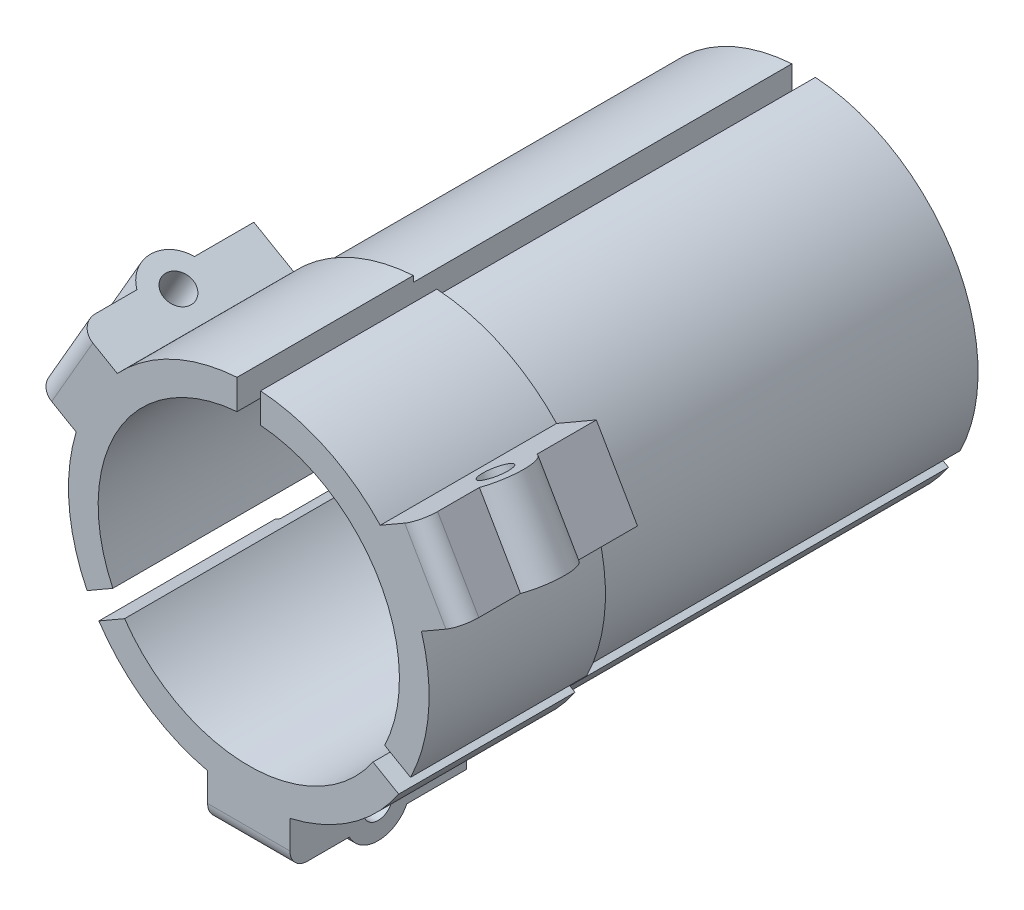
from build123d import *

# Parameters (mm, degrees)
BOSS_EXTRUDE1_DEPTH   = 11.9888
BOSS_EXTRUDE1_2_DEPTH = 11.9888
BOSS_EXTRUDE1_3_DEPTH = 11.9888
BOSS_EXTRUDE2_START   = -3.81
BOSS_EXTRUDE2_DEPTH   = 3.81
BOSS_EXTRUDE3_START   = -3.81
BOSS_EXTRUDE3_DEPTH   = 3.81
FILLET1_R             = 0.381
FILLET2_R             = 0.381
FILLET3_R             = 0.381
BOSS_EXTRUDE4_DEPTH   = 1.778
SKETCH5_6_R           = 0.3175
CUT_EXTRUDE1_DEPTH    = 1.778
BOSS_EXTRUDE5_DEPTH   = 1.778
CUT_EXTRUDE2_DEPTH    = 14.935215559
BOSS_EXTRUDE6_DEPTH   = 1.778
CUT_EXTRUDE3_DEPTH    = 15.288111882


with BuildPart() as part:
    # Sketch1 → Boss-Extrude1 (new body)
    with BuildSketch(Plane.XY):
        with BuildLine():
            Line((-0.254, 3.760702479), (-0.254, 3.244994166))
            ThreePointArc((-0.254, 3.244994166), (-2.818843265, 1.627459918), (-2.937247383, -1.402526631))
            Line((-2.937247383, -1.402526631), (-3.383863883, -1.660380787))
            ThreePointArc((-3.383863883, -1.660380787), (-3.264283896, 1.884635186), (-0.254, 3.760702479))
        make_face()
    extrude(amount=BOSS_EXTRUDE1_DEPTH)



with BuildPart() as body_2:
    # Sketch1 → Boss-Extrude1 2 (new body)
    with BuildSketch(Plane.XY):
        with BuildLine():
            Line((0.254, 3.760702479), (0.254, 3.244994166))
            ThreePointArc((0.254, 3.244994166), (2.818843265, 1.627459918), (2.937247383, -1.402526631))
            Line((2.937247383, -1.402526631), (3.383863883, -1.660380787))
            ThreePointArc((3.383863883, -1.660380787), (3.264283896, 1.884635186), (0.254, 3.760702479))
        make_face()
    extrude(amount=BOSS_EXTRUDE1_2_DEPTH)


with BuildPart() as body_3:
    # Sketch1 → Boss-Extrude1 3 (new body)
    with BuildSketch(Plane.XY):
        with BuildLine():
            Line((3.129863883, -2.100321692), (2.683247383, -1.842467536))
            ThreePointArc((2.683247383, -1.842467536), (0, -3.254919836), (-2.683247383, -1.842467536))
            Line((-2.683247383, -1.842467536), (-3.129863883, -2.100321692))
            ThreePointArc((-3.129863883, -2.100321692), (0, -3.769270372), (3.129863883, -2.100321692))
        make_face()
    extrude(amount=BOSS_EXTRUDE1_3_DEPTH)


with BuildPart() as part_1:
    add(part.part)

    add(body_2.part)  # Boss-Extrude2 merges body 2

    add(body_3.part)  # Boss-Extrude2 merges body 3
    # Sketch2 → Boss-Extrude2 (add)
    with BuildSketch(Plane.XY.offset(11.9888).offset(BOSS_EXTRUDE2_START)):
        with BuildLine():
            Line((-0.254, 3.760702479), (-0.254, 3.887982358))
            ThreePointArc((-0.254, 3.887982358), (-3.374269122, 1.948135186), (-3.494091491, -1.724020726))
            Line((-3.494091491, -1.724020726), (-3.383863883, -1.660380787))
            ThreePointArc((-3.383863883, -1.660380787), (-3.264283896, 1.884635186), (-0.254, 3.760702479))
        make_face()
        with BuildLine():
            Line((0.254, 3.887982358), (0.254, 3.760702479))
            ThreePointArc((0.254, 3.760702479), (3.264283896, 1.884635186), (3.383863883, -1.660380787))
            Line((3.383863883, -1.660380787), (3.494091491, -1.724020726))
            ThreePointArc((3.494091491, -1.724020726), (3.374269122, 1.948135186), (0.254, 3.887982358))
        make_face()
        with BuildLine():
            Line((3.240091491, -2.163961631), (3.129863883, -2.100321692))
            ThreePointArc((3.129863883, -2.100321692), (0, -3.769270372), (-3.129863883, -2.100321692))
            Line((-3.129863883, -2.100321692), (-3.240091491, -2.163961631))
            ThreePointArc((-3.240091491, -2.163961631), (0, -3.896270372), (3.240091491, -2.163961631))
        make_face()
    extrude(amount=BOSS_EXTRUDE2_DEPTH)

    # Sketch4 → Boss-Extrude3 (add)
    with BuildSketch(Plane.XY.offset(11.9888).offset(BOSS_EXTRUDE3_START)):
        with BuildLine():
            Line((-2.840762754, 2.666643919), (-3.699665706, 3.16253177))
            Line((-3.699665706, 3.16253177), (-4.588665706, 1.622738602))
            Line((-4.588665706, 1.622738602), (-3.729762754, 1.126850751))
            ThreePointArc((-3.729762754, 1.126850751), (-3.374269122, 1.948135186), (-2.840762754, 2.666643919))
        make_face()
        with BuildLine():
            Line((-0.889, -3.79349467), (-0.889, -4.785270372))
            Line((-0.889, -4.785270372), (0.889, -4.785270372))
            Line((0.889, -4.785270372), (0.889, -3.79349467))
            ThreePointArc((0.889, -3.79349467), (0, -3.896270372), (-0.889, -3.79349467))
        make_face()
        with BuildLine():
            Line((3.729762754, 1.126850751), (4.588665706, 1.622738602))
            Line((4.588665706, 1.622738602), (3.699665706, 3.16253177))
            Line((3.699665706, 3.16253177), (2.840762754, 2.666643919))
            ThreePointArc((2.840762754, 2.666643919), (3.374269122, 1.948135186), (3.729762754, 1.126850751))
        make_face()
    extrude(amount=BOSS_EXTRUDE3_DEPTH)

    # Fillet1
    fillet1_edges = [part_1.edges().sort_by_distance(p)[0] for p in [
        (-4.144165706, 2.392635186, 11.9888),
    ]]
    fillet(fillet1_edges, radius=FILLET1_R)

    # Fillet2
    fillet2_edges = [part_1.edges().sort_by_distance(p)[0] for p in [
        (0, -4.785270372, 11.9888),
    ]]
    fillet(fillet2_edges, radius=FILLET2_R)

    # Fillet3
    fillet3_edges = [part_1.edges().sort_by_distance(p)[0] for p in [
        (4.144165706, 2.392635186, 11.9888),
    ]]
    fillet(fillet3_edges, radius=FILLET3_R)

    # Sketch5 → Boss-Extrude4 (add)
    with BuildSketch(Plane(origin=(-0.4445, 0.769896584, 0), x_dir=(0.8660254037844434, 0.4999999999999918, 0), z_dir=(-0.4999999999999918, 0.8660254037844434, 0))):
        with BuildLine():
            ThreePointArc((4.785270372, -10.705970395), (5.166270372, -10.0838), (4.785270372, -9.461629605))
            Line((4.785270372, -9.461629605), (4.785270372, -10.0838))
            Line((4.785270372, -10.0838), (4.785270372, -10.705970395))
        make_face()
    extrude(amount=-BOSS_EXTRUDE4_DEPTH)

    # Sketch5_6 → Cut-Extrude1 (cut)
    with BuildSketch(Plane(origin=(-0.4445, 0.769896584, 0), x_dir=(0.8660254037844434, 0.4999999999999918, 0), z_dir=(-0.4999999999999918, 0.8660254037844434, 0))):
        with Locations((4.467770372, -10.0838)):
            Circle(SKETCH5_6_R)
    extrude(amount=-CUT_EXTRUDE1_DEPTH, mode=Mode.SUBTRACT)

    # Sketch6 → Boss-Extrude5 (add)
    with BuildSketch(Plane(origin=(-0.4445, -0.769896584, 0), x_dir=(0.8660254037844363, -0.5000000000000043, 0), z_dir=(-0.5000000000000042, -0.8660254037844362, 0))):
        with BuildLine():
            ThreePointArc((-4.785270372, 10.705970395), (-5.166270372, 10.0838), (-4.785270372, 9.461629605))
            Line((-4.785270372, 9.461629605), (-4.785270372, 10.0838))
            Line((-4.785270372, 10.0838), (-4.785270372, 10.705970395))
        make_face()
    extrude(amount=-BOSS_EXTRUDE5_DEPTH)

    # Sketch6_3 → Cut-Extrude2 (cut, through all)
    with BuildSketch(Plane(origin=(-0.4445, -0.769896584, 0), x_dir=(0.8660254037844363, -0.5000000000000043, 0), z_dir=(-0.5000000000000042, -0.8660254037844362, 0))):
        with BuildLine():
            ThreePointArc((-4.150270372, 10.0838), (-4.467770372, 10.4013), (-4.785270372, 10.0838))
            ThreePointArc((-4.785270372, 10.0838), (-4.467770372, 9.7663), (-4.150270372, 10.0838))
        make_face()
    extrude(amount=-CUT_EXTRUDE2_DEPTH, mode=Mode.SUBTRACT)

    # Sketch7 → Boss-Extrude6 (add)
    with BuildSketch(Plane(origin=(0.889, 0, 0), x_dir=(0, 0, -1), z_dir=(1, 0, 0))):
        with BuildLine():
            ThreePointArc((-10.705970395, -4.785270372), (-10.0838, -5.166270372), (-9.461629605, -4.785270372))
            Line((-9.461629605, -4.785270372), (-10.0838, -4.785270372))
            Line((-10.0838, -4.785270372), (-10.705970395, -4.785270372))
        make_face()
    extrude(amount=-BOSS_EXTRUDE6_DEPTH)

    # Sketch7_3 → Cut-Extrude3 (cut, through all)
    with BuildSketch(Plane(origin=(0.889, 0, 0), x_dir=(0, 0, -1), z_dir=(1, 0, 0))):
        with BuildLine():
            ThreePointArc((-9.7663, -4.467770372), (-10.308306403, -4.243263969), (-10.0838, -4.785270372))
            ThreePointArc((-10.0838, -4.785270372), (-9.859293597, -4.692276775), (-9.7663, -4.467770372))
        make_face()
    extrude(amount=-CUT_EXTRUDE3_DEPTH, mode=Mode.SUBTRACT)


solid = part_1.part
